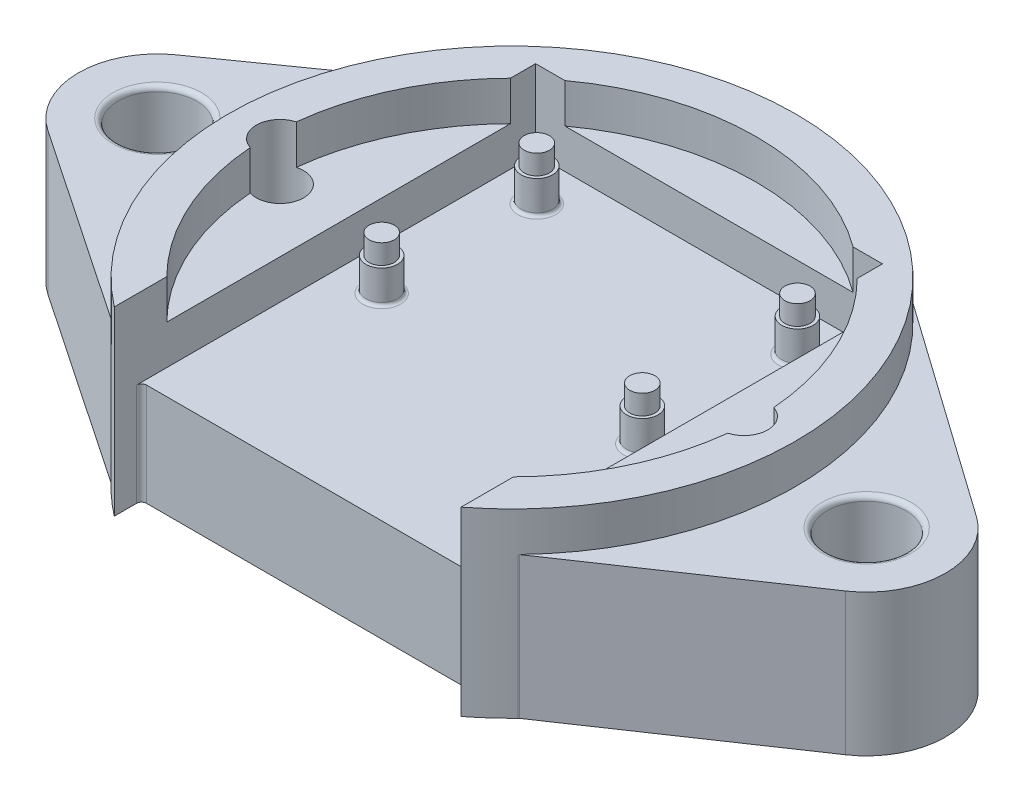
from build123d import *

# Parameters (mm, degrees)
SKETCH1_R               = 22.843403387
SKETCH1_W               = 25.4
SKETCH1_H               = 25.4
BOSS_EXTRUDE1_DEPTH     = 3.175
SKETCH3_R               = 22.843403387
SKETCH3_R_2             = 19.668403387
BOSS_EXTRUDE2_DEPTH     = 3.175
SKETCH4_R               = 22.843403387
BOSS_EXTRUDE3_DEPTH     = 3.175
SKETCH14_W              = 25.4
SKETCH14_H              = 3.175
CUT_EXTRUDE5_DEPTH      = 3.175
CUT_EXTRUDE5_DEPTH_BACK = 3.175
SKETCH18_W              = 27.94
SKETCH18_H              = 31.75
CUT_EXTRUDE7_DEPTH      = 4.175
CUT_EXTRUDE7_DEPTH_BACK = 3.175
SKETCH7_W               = 27.94
SKETCH7_H               = 25.4
CUT_EXTRUDE1_DEPTH      = 10.525
SKETCH9_R               = 1.27
BOSS_EXTRUDE4_DEPTH     = 2.654
SKETCH12_R              = 1.905
CUT_EXTRUDE3_DEPTH      = 1
CUT_EXTRUDE3_DEPTH_BACK = 10.525
SKETCH15_R              = 3.175
BOSS_EXTRUDE5_DEPTH     = 6.35
SKETCH17_R              = 3.175
BOSS_EXTRUDE6_DEPTH     = 5.08
CUT_EXTRUDE6_DEPTH      = 5.08
FILLET1_R               = 0.254
FILLET2_R               = 0.396875
CHAMFER2_SIZE           = 0.3175
CHAMFER2_SIZE2          = 1.800631978
SKETCH20_R              = 1.016
BOSS_EXTRUDE8_DEPTH     = 1.5875


with BuildPart() as part:
    # Sketch1 → Boss-Extrude1 (new body)
    with BuildSketch(Plane(origin=(0, 0, 0), x_dir=(1, 0, 0), z_dir=(0, 1, 0))):
        Circle(SKETCH1_R)
        Rectangle(SKETCH1_W, SKETCH1_H, mode=Mode.SUBTRACT)
    extrude(amount=-BOSS_EXTRUDE1_DEPTH)

    # Sketch3 → Boss-Extrude2 (add)
    with BuildSketch(Plane(origin=(0, 0, 0), x_dir=(1, 0, 0), z_dir=(0, 1, 0))):
        Circle(SKETCH3_R)
        Circle(SKETCH3_R_2, mode=Mode.SUBTRACT)
    extrude(amount=BOSS_EXTRUDE2_DEPTH)

    # Sketch4 → Boss-Extrude3 (add)
    with BuildSketch(Plane.XZ.offset(3.175)):
        Circle(SKETCH4_R)
    extrude(amount=BOSS_EXTRUDE3_DEPTH)

    # Sketch14 → Cut-Extrude5 (cut, two sides)
    with BuildSketch(Plane(origin=(0, 0, 0), x_dir=(1, 0, 0), z_dir=(0, 1, 0))) as cut_extrude5_sk:
        with Locations((0, 14.2875)):
            Rectangle(SKETCH14_W, SKETCH14_H)
    extrude(amount=CUT_EXTRUDE5_DEPTH, mode=Mode.SUBTRACT)
    extrude(cut_extrude5_sk.sketch, amount=-CUT_EXTRUDE5_DEPTH_BACK, mode=Mode.SUBTRACT)

    # Sketch18 → Cut-Extrude7 (cut, two sides)
    with BuildSketch(Plane(origin=(0, 0, 0), x_dir=(1, 0, 0), z_dir=(0, 1, 0))) as cut_extrude7_sk:
        Rectangle(SKETCH18_W, SKETCH18_H)
    extrude(amount=CUT_EXTRUDE7_DEPTH, mode=Mode.SUBTRACT)
    extrude(cut_extrude7_sk.sketch, amount=-CUT_EXTRUDE7_DEPTH_BACK, mode=Mode.SUBTRACT)

    # Sketch7 → Cut-Extrude1 (cut, through all)
    with BuildSketch(Plane(origin=(0, 3.175, 0), x_dir=(1, 0, 0), z_dir=(0, 1, 0))):
        with Locations((0, -28.575)):
            Rectangle(SKETCH7_W, SKETCH7_H)
    extrude(amount=-CUT_EXTRUDE1_DEPTH, mode=Mode.SUBTRACT)

    # Sketch9 → Boss-Extrude4 (add)
    with BuildSketch(Plane(origin=(0, -3.175, 0), x_dir=(1, 0, 0), z_dir=(0, 1, 0))):
        with Locations((-10.5, 12.5)):
            Circle(SKETCH9_R)
        with Locations((10.5, 12.5)):
            Circle(SKETCH9_R)
        with Locations((10.5, 0)):
            Circle(SKETCH9_R)
        with Locations((-10.5, 0)):
            Circle(SKETCH9_R)
    extrude(amount=BOSS_EXTRUDE4_DEPTH)

    # Sketch12 → Cut-Extrude3 (cut, two sides)
    with BuildSketch(Plane(origin=(0, 3.175, 0), x_dir=(1, 0, 0), z_dir=(0, 1, 0))) as cut_extrude3_sk:
        with Locations((-19.030417336, 0.337135758)):
            Circle(SKETCH12_R)
        with Locations((19.030417335, -0.337135758)):
            Circle(SKETCH12_R)
    extrude(amount=CUT_EXTRUDE3_DEPTH, mode=Mode.SUBTRACT)
    extrude(cut_extrude3_sk.sketch, amount=-CUT_EXTRUDE3_DEPTH_BACK, mode=Mode.SUBTRACT)

    # Sketch15 → Boss-Extrude5 (add)
    with BuildSketch(Plane.XZ.offset(6.35)):
        with BuildLine():
            ThreePointArc((16.425755791, 15.875), (22.743458946, -2.134514804), (13.185143195, -18.654036486))
            Line((13.185143195, -18.654036486), (32.240200753, -5.18544149))
            ThreePointArc((32.240200753, -5.18544149), (34.924650877, 0.066586344), (32.130651226, 5.261163784))
            Line((32.130651226, 5.261163784), (16.425755791, 15.875))
        make_face()
        with Locations((28.575, 0)):
            Circle(SKETCH15_R, mode=Mode.SUBTRACT)
        with BuildLine():
            ThreePointArc((-13.185143195, -18.654036486), (-22.743458946, -2.134514804), (-16.425755791, 15.875))
            Line((-16.425755791, 15.875), (-32.130651226, 5.261163784))
            ThreePointArc((-32.130651226, 5.261163784), (-34.924650877, 0.066586344), (-32.240200753, -5.18544149))
            Line((-32.240200753, -5.18544149), (-13.185143195, -18.654036486))
        make_face()
        with Locations((-28.575, 0)):
            Circle(SKETCH15_R, mode=Mode.SUBTRACT)
    extrude(amount=-BOSS_EXTRUDE5_DEPTH)

    # Sketch17 → Boss-Extrude6 (add)
    with BuildSketch(Plane.XZ.offset(6.35)):
        with BuildLine():
            Line((-13.97, 15.875), (13.97, 15.875))
            Line((13.97, 15.875), (13.97, 18.073742786))
            ThreePointArc((13.97, 18.073742786), (15.237588719, 17.018724051), (16.425755791, 15.875))
            Line((16.425755791, 15.875), (32.130651226, 5.261163784))
            ThreePointArc((32.130651226, 5.261163784), (34.924650877, 0.066586344), (32.240200753, -5.18544149))
            Line((32.240200753, -5.18544149), (13.185143195, -18.654036486))
            ThreePointArc((13.185143195, -18.654036486), (0, -22.843403387), (-13.185143195, -18.654036486))
            Line((-13.185143195, -18.654036486), (-32.240200753, -5.18544149))
            ThreePointArc((-32.240200753, -5.18544149), (-34.924650877, 0.066586344), (-32.130651226, 5.261163784))
            Line((-32.130651226, 5.261163784), (-16.425755791, 15.875))
            ThreePointArc((-16.425755791, 15.875), (-15.237588719, 17.018724051), (-13.97, 18.073742786))
            Line((-13.97, 18.073742786), (-13.97, 15.875))
        make_face()
        with Locations((-28.575, 0)):
            Circle(SKETCH17_R, mode=Mode.SUBTRACT)
        with Locations((28.575, 0)):
            Circle(SKETCH17_R, mode=Mode.SUBTRACT)
    extrude(amount=BOSS_EXTRUDE6_DEPTH)

    # Sketch16 → Cut-Extrude6 (cut)
    with BuildSketch(Plane(origin=(0, -11.43, 0), x_dir=(-1, 0, 0), z_dir=(0, -1, 0))):
        Polygon((13.897773442, 0.337135758), (16.464095389, -4.107864242), (21.596739282, -4.107864242), (24.163061229, 0.337135758), (21.596739282, 4.782135758), (16.464095389, 4.782135758), align=None)
        Polygon((-16.464095389, 4.107864242), (-21.596739282, 4.107864242), (-24.163061229, -0.337135758), (-21.596739282, -4.782135758), (-16.464095389, -4.782135758), (-13.897773442, -0.337135758), align=None)
    extrude(amount=-CUT_EXTRUDE6_DEPTH, mode=Mode.SUBTRACT)

    # Fillet1
    fillet1_edges = [part.edges().sort_by_distance(p)[0] for p in [
        (-11.77, -3.175, -12.5),
        (9.23, -3.175, -12.5),
        (9.23, -3.175, 0),
        (-11.77, -3.175, 0),
    ]]
    fillet(fillet1_edges, radius=FILLET1_R)

    # Fillet2
    fillet2_edges = [part.edges().sort_by_distance(p)[0] for p in [
        (-13.97, -7.3025, 15.875),
        (13.97, -7.3025, 15.875),
        (16.425755791, -3.175, 15.875),
        (25.4, 0, 0),
        (-16.425755791, -3.175, 15.875),
        (-31.75, 0, 0),
    ]]
    fillet(fillet2_edges, radius=FILLET2_R)

    # Chamfer2
    chamfer2_edges = [part.edges().sort_by_distance(p)[0] for p in [
        (-15.180934416, -11.43, -2.559635758),
        (-15.180934416, -11.43, 1.885364242),
        (-19.030417336, -11.43, 4.107864242),
        (-22.879900255, -11.43, 1.885364242),
        (-22.879900255, -11.43, -2.559635758),
        (-19.030417336, -11.43, -4.782135758),
        (15.180934416, -11.43, -1.885364242),
        (19.030417335, -11.43, -4.107864242),
        (22.879900255, -11.43, -1.885364242),
        (22.879900255, -11.43, 2.559635758),
        (19.030417335, -11.43, 4.782135758),
        (15.180934416, -11.43, 2.559635758),
    ]]
    chamfer2_side = [part.faces().sort_by_distance(p)[0] for p in [
        (0, -11.43, -1.727723588),
    ]]
    chamfer(chamfer2_edges, length=CHAMFER2_SIZE, length2=CHAMFER2_SIZE2, reference=chamfer2_side[0])

    # Sketch20 → Boss-Extrude8 (add)
    with BuildSketch(Plane(origin=(0, -0.521, 0), x_dir=(1, 0, 0), z_dir=(0, 1, 0))):
        with Locations((10.5, 12.5)):
            Circle(SKETCH20_R)
        with Locations((10.5, 0)):
            Circle(SKETCH20_R)
        with Locations((-10.5, 0)):
            Circle(SKETCH20_R)
        with Locations((-10.5, 12.5)):
            Circle(SKETCH20_R)
    extrude(amount=BOSS_EXTRUDE8_DEPTH)


solid = part.part
